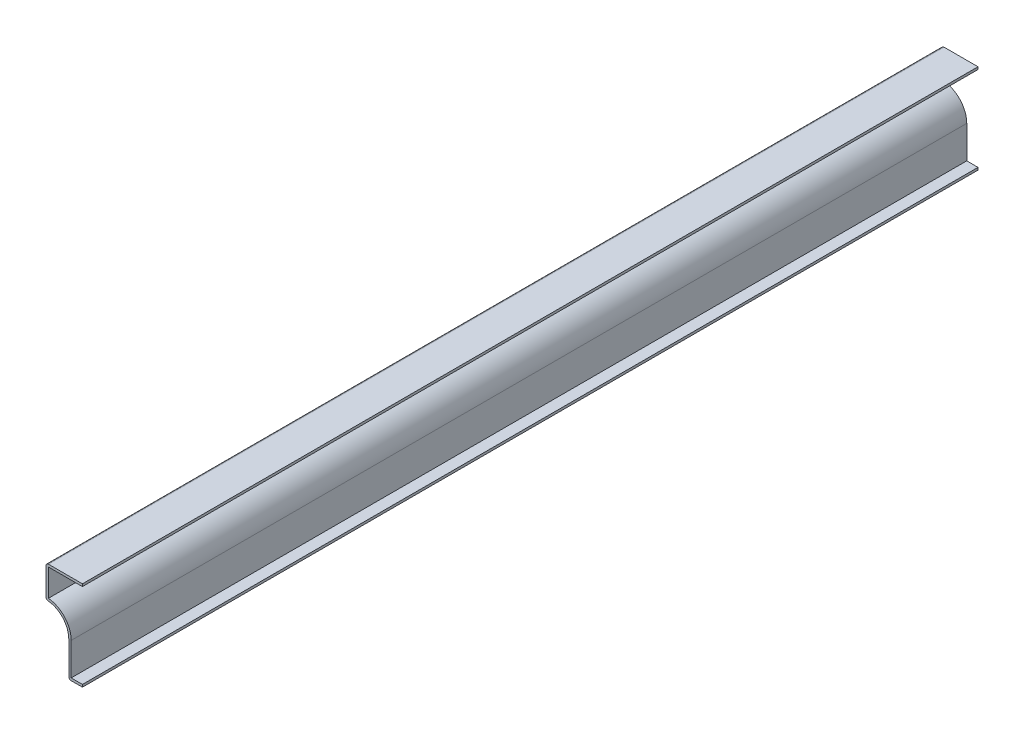
from build123d import *

# Parameters (mm, degrees)
EXTRUDE_THIN1_DEPTH = 468.3125
FILLET1_R           = 1.27


with BuildPart() as part:
    # Sketch1 → Extrude-Thin1 (new body)
    with BuildSketch(Plane.XY):
        with BuildLine():
            Line((0, 46.83125), (-19.05, 46.83125))
            Line((-19.05, 46.83125), (-19.05, 30.1625))
            ThreePointArc((-19.05, 30.1625), (-10.631009886, 26.675240114), (-7.14375, 18.25625))
            Line((-7.14375, 18.25625), (-7.14375, 0))
            Line((-7.14375, 0), (0, 0))
            Line((0, 0), (0, 1.27))
            Line((0, 1.27), (-5.87375, 1.27))
            Line((-5.87375, 1.27), (-5.87375, 18.25625))
            ThreePointArc((-5.87375, 18.25625), (-9.294299063, 27.112878212), (-17.78, 31.371152366))
            Line((-17.78, 31.371152366), (-17.78, 45.56125))
            Line((-17.78, 45.56125), (0, 45.56125))
            Line((0, 45.56125), (0, 46.83125))
        make_face()
    extrude(amount=-EXTRUDE_THIN1_DEPTH)

    # Fillet1
    fillet1_edges = [part.edges().sort_by_distance(p)[0] for p in [
        (-7.14375, 0, -234.15625),
        (-19.05, 30.1625, -234.15625),
        (-19.05, 46.83125, -234.15625),
    ]]
    fillet(fillet1_edges, radius=FILLET1_R)


solid = part.part
